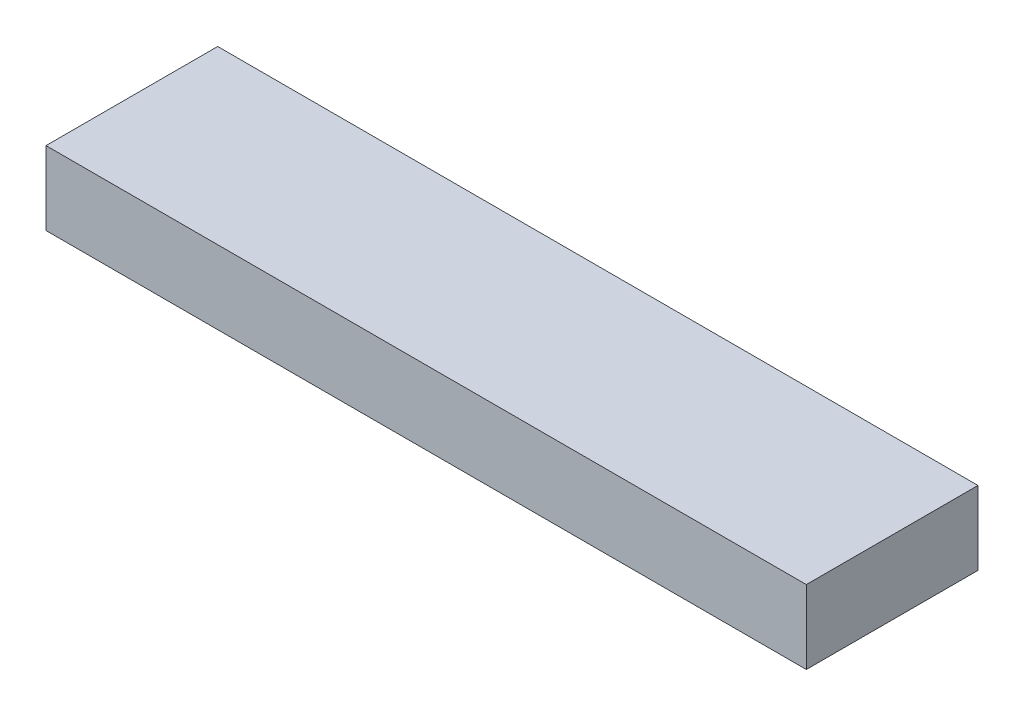
from build123d import *

# Parameters (mm, degrees)
SKETCH1_W           = 393.7
SKETCH1_H           = 88.9
BOSS_EXTRUDE1_DEPTH = 38.1


with BuildPart() as part:
    # Sketch1 → Boss-Extrude1 (new body)
    with BuildSketch(Plane(origin=(0, 0, 0), x_dir=(1, 0, 0), z_dir=(0, 1, 0))):
        with Locations((196.85, 44.45)):
            Rectangle(SKETCH1_W, SKETCH1_H)
    extrude(amount=BOSS_EXTRUDE1_DEPTH)


solid = part.part
